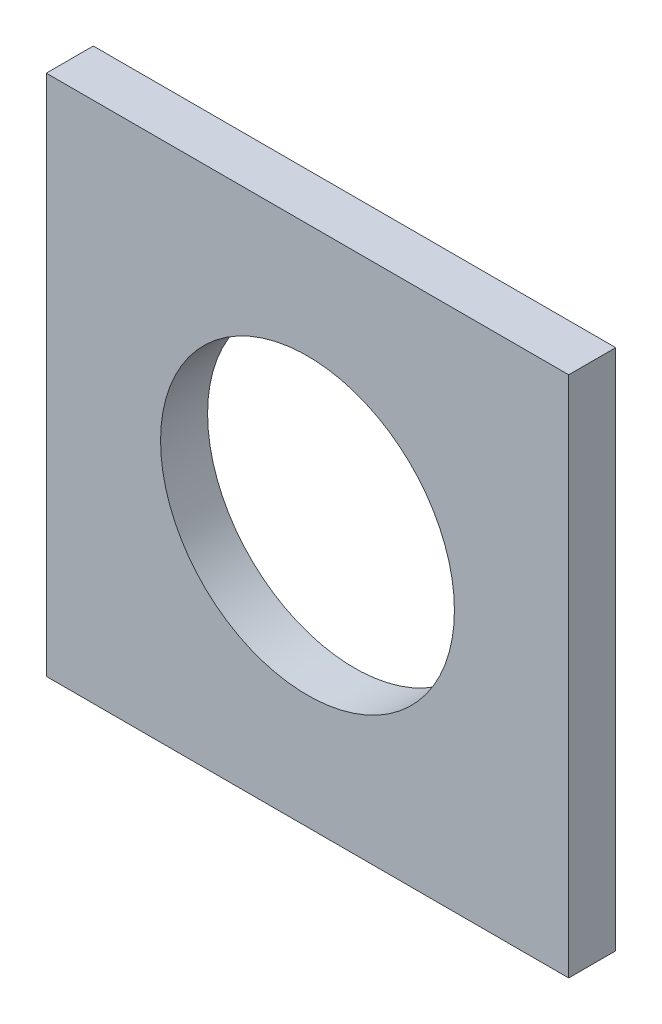
from build123d import *

# Parameters (mm, degrees)
SKETCH1_W           = 50.8
SKETCH1_H           = 50.8
BOSS_EXTRUDE1_DEPTH = 4.572
CUT_EXTRUDE1_DEPTH  = 4.572


with BuildPart() as part:
    # Sketch1 → Boss-Extrude1 (new body)
    with BuildSketch(Plane.XY):
        with Locations((6.5024, -6.366933333)):
            Rectangle(SKETCH1_W, SKETCH1_H)
    extrude(amount=BOSS_EXTRUDE1_DEPTH)

    # Sketch2 → Cut-Extrude1 (cut)
    with BuildSketch(Plane(origin=(0, 0, 0), x_dir=(-1, 0, 0), z_dir=(0, 0, -1))):
        with BuildLine():
            ThreePointArc((7.7851, -6.366933333), (3.600388136, 3.735854803), (-6.5024, 7.920566667))
            Line((-6.5024, 7.920566667), (-6.5024, -6.366933333))
            Line((-6.5024, -6.366933333), (7.7851, -6.366933333))
        make_face()
        with BuildLine():
            Line((-6.5024, -6.366933333), (-6.5024, 7.920566667))
            ThreePointArc((-6.5024, 7.920566667), (-16.605188136, 3.735854803), (-20.7899, -6.366933333))
            Line((-20.7899, -6.366933333), (-6.5024, -6.366933333))
        make_face()
        with BuildLine():
            Line((7.7851, -6.366933333), (-6.5024, -6.366933333))
            Line((-6.5024, -6.366933333), (-6.5024, -20.654433333))
            ThreePointArc((-6.5024, -20.654433333), (3.600388136, -16.46972147), (7.7851, -6.366933333))
        make_face()
        with BuildLine():
            Line((-6.5024, -20.654433333), (-6.5024, -6.366933333))
            Line((-6.5024, -6.366933333), (-20.7899, -6.366933333))
            ThreePointArc((-20.7899, -6.366933333), (-16.605188136, -16.46972147), (-6.5024, -20.654433333))
        make_face()
    extrude(amount=-CUT_EXTRUDE1_DEPTH, mode=Mode.SUBTRACT)


solid = part.part
